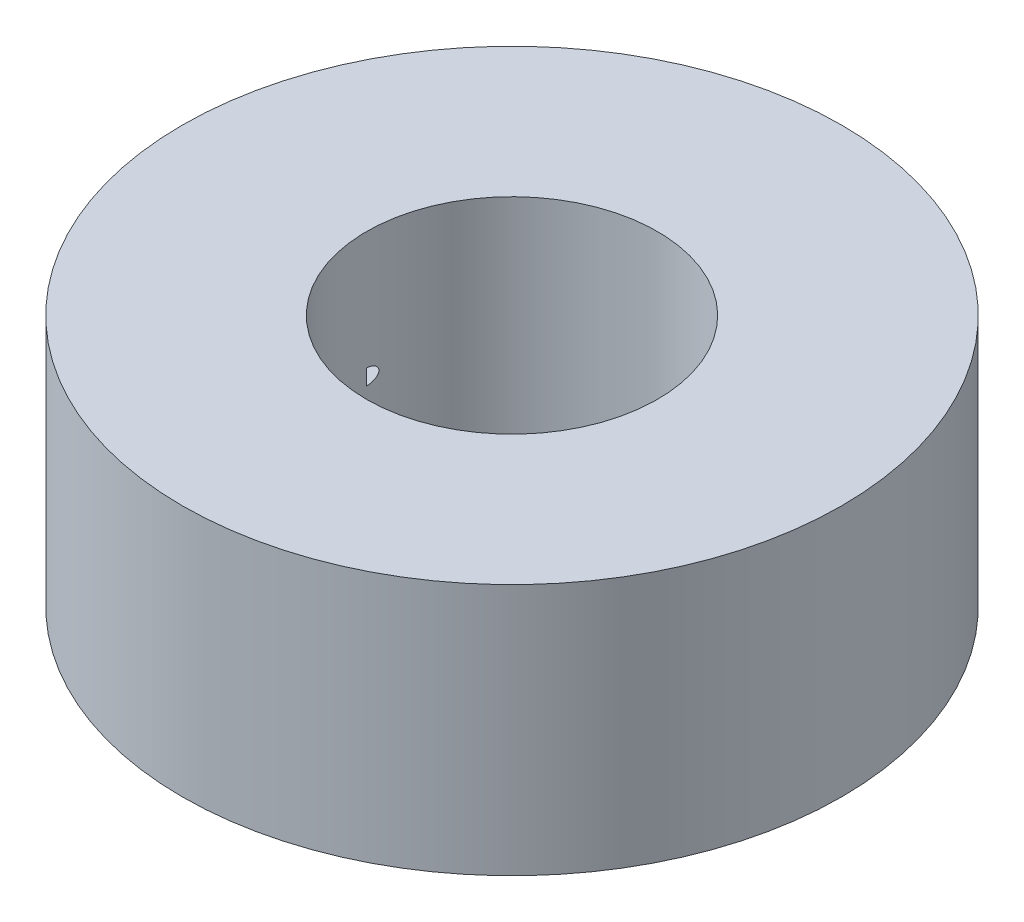
from build123d import *

# Parameters (mm, degrees)
SKETCH1_R           = 17
SKETCH1_R_2         = 7.5
BOSS_EXTRUDE1_DEPTH = 13
SKETCH2_R           = 3.175
CUT_EXTRUDE1_DEPTH  = 18


with BuildPart() as part:
    # Sketch1 → Boss-Extrude1 (new body)
    with BuildSketch(Plane(origin=(0, 0, 0), x_dir=(1, 0, 0), z_dir=(0, 1, 0))):
        Circle(SKETCH1_R)
        Circle(SKETCH1_R_2, mode=Mode.SUBTRACT)
    extrude(amount=BOSS_EXTRUDE1_DEPTH)

    # Sketch2 → Cut-Extrude1 (cut, through all)
    with BuildSketch(Plane.XY):
        with Locations((-10.65, 6.5)):
            Circle(SKETCH2_R)
    extrude(amount=-CUT_EXTRUDE1_DEPTH, mode=Mode.SUBTRACT)


solid = part.part
